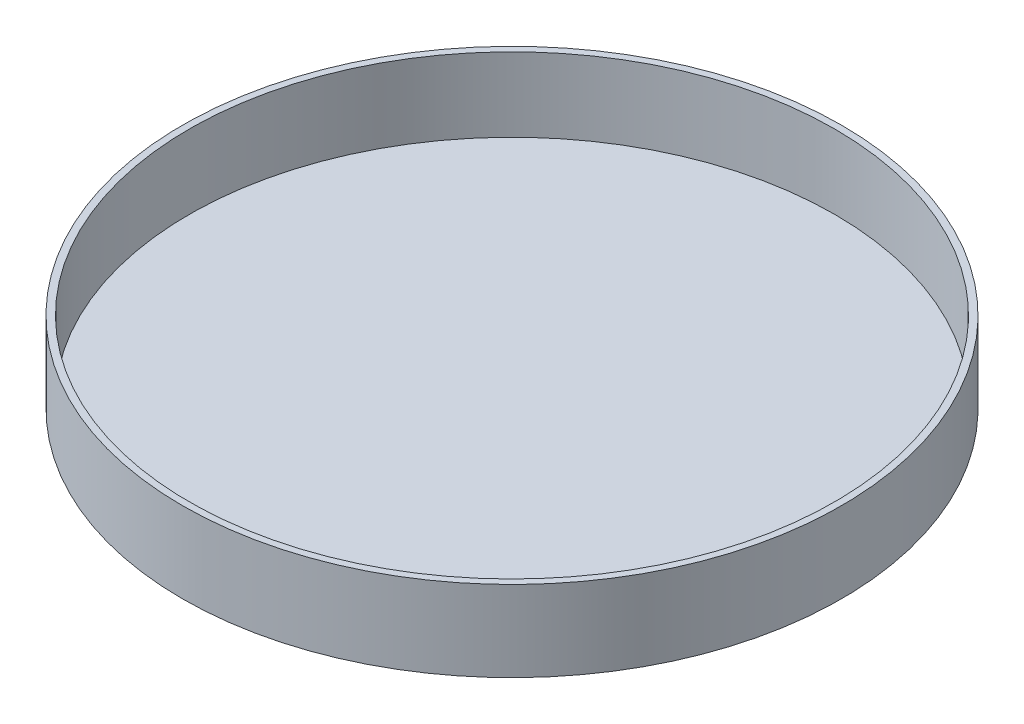
from build123d import *


with BuildPart() as part:
    # Sketch1 → Revolve1 (revolve)
    with BuildSketch(Plane(origin=(0, 0, 0), x_dir=(0, 0, -1), z_dir=(1, 0, 0)), mode=Mode.PRIVATE) as revolve1_sk:
        Polygon((0, 0), (-311.15, 0), (-311.15, 76.2), (-304.8, 76.2), (-304.8, 6.35), (0, 6.35), align=None)
    revolve(revolve1_sk.sketch.rotate(Axis((0, -45.633687212, 0), (0, 1, 0)), 180), axis=Axis((0, -45.633687212, 0), (0, 1, 0)))  # turned: the seam where the file's is


solid = part.part
